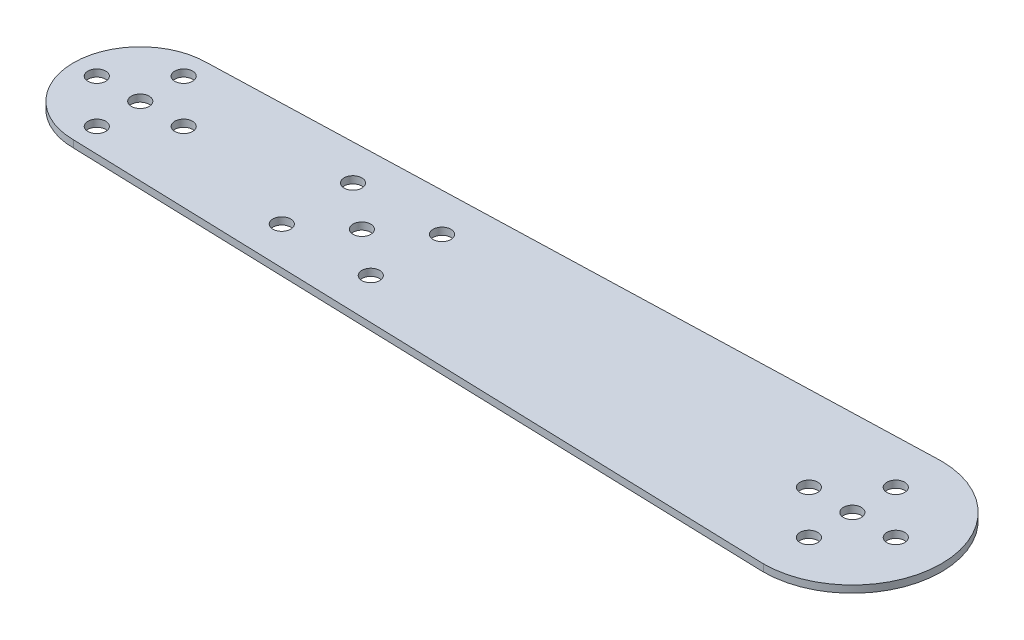
from build123d import *

# Parameters (mm, degrees)
BOSS_EXTRUDE1_DEPTH       = 2
F_5_0MM_DOWEL_HOLE1_D     = 5
F_5_0MM_DOWEL_HOLE1_DEPTH = 2
CUT_EXTRUDE1_REACH        = 4
SKETCH4_R                 = 2.5
CUT_EXTRUDE2_REACH        = 4
SKETCH16_R                = 2.5


with BuildPart() as part:
    # Sketch2 → Boss-Extrude1 (new body)
    with BuildSketch(Plane(origin=(0, 0, 0), x_dir=(1, 0, 0), z_dir=(0, 1, 0))):
        with BuildLine():
            Line((100, 25), (-100, 18.75))
            ThreePointArc((-100, 18.75), (-118.75, 0), (-100, -18.75))
            Line((-100, -18.75), (100, -25))
            ThreePointArc((100, -25), (125, 0), (100, 25))
        make_face()
    extrude(amount=BOSS_EXTRUDE1_DEPTH)

    # Ø5.0mm Dowel Hole1
    with Locations(Plane(origin=(0, 2, 0), x_dir=(1, 0, 0), z_dir=(0, 1, 0))):
        with Locations((100, 0), (-100, 0)):
            Hole(F_5_0MM_DOWEL_HOLE1_D / 2, depth=F_5_0MM_DOWEL_HOLE1_DEPTH)

    # Sketch4 → Cut-Extrude1 (cut, up to next)
    with BuildSketch(Plane(origin=(0, 2, 0), x_dir=(1, 0, 0), z_dir=(0, 1, 0)), mode=Mode.PRIVATE) as cut_extrude1_sk1:
        with Locations((100, 12.2)):
            Circle(SKETCH4_R)
    cut_extrude1_tool1 = extrude(cut_extrude1_sk1.sketch, amount=-CUT_EXTRUDE1_REACH, mode=Mode.PRIVATE) & part.part
    add(cut_extrude1_tool1.solids().sort_by_distance((100, 2, -12.2))[0], mode=Mode.SUBTRACT)
    # Sketch4 → Cut-Extrude1 (cut, up to next)
    with BuildSketch(Plane(origin=(0, 2, 0), x_dir=(1, 0, 0), z_dir=(0, 1, 0)), mode=Mode.PRIVATE) as cut_extrude1_sk2:
        with Locations((100, -12.2)):
            Circle(SKETCH4_R)
    cut_extrude1_tool2 = extrude(cut_extrude1_sk2.sketch, amount=-CUT_EXTRUDE1_REACH, mode=Mode.PRIVATE) & part.part
    add(cut_extrude1_tool2.solids().sort_by_distance((100, 2, 12.2))[0], mode=Mode.SUBTRACT)
    # Sketch4 → Cut-Extrude1 (cut, up to next)
    with BuildSketch(Plane(origin=(0, 2, 0), x_dir=(1, 0, 0), z_dir=(0, 1, 0)), mode=Mode.PRIVATE) as cut_extrude1_sk3:
        with Locations((112.2, 0)):
            Circle(SKETCH4_R)
    cut_extrude1_tool3 = extrude(cut_extrude1_sk3.sketch, amount=-CUT_EXTRUDE1_REACH, mode=Mode.PRIVATE) & part.part
    add(cut_extrude1_tool3.solids().sort_by_distance((112.2, 2, 0))[0], mode=Mode.SUBTRACT)
    # Sketch4 → Cut-Extrude1 (cut, up to next)
    with BuildSketch(Plane(origin=(0, 2, 0), x_dir=(1, 0, 0), z_dir=(0, 1, 0)), mode=Mode.PRIVATE) as cut_extrude1_sk4:
        with Locations((87.8, 0)):
            Circle(SKETCH4_R)
    cut_extrude1_tool4 = extrude(cut_extrude1_sk4.sketch, amount=-CUT_EXTRUDE1_REACH, mode=Mode.PRIVATE) & part.part
    add(cut_extrude1_tool4.solids().sort_by_distance((87.8, 2, 0))[0], mode=Mode.SUBTRACT)
    # Sketch4 → Cut-Extrude1 (cut, up to next)
    with BuildSketch(Plane(origin=(0, 2, 0), x_dir=(1, 0, 0), z_dir=(0, 1, 0)), mode=Mode.PRIVATE) as cut_extrude1_sk5:
        with Locations((-100, 12.2)):
            Circle(SKETCH4_R)
    cut_extrude1_tool5 = extrude(cut_extrude1_sk5.sketch, amount=-CUT_EXTRUDE1_REACH, mode=Mode.PRIVATE) & part.part
    add(cut_extrude1_tool5.solids().sort_by_distance((-100, 2, -12.2))[0], mode=Mode.SUBTRACT)
    # Sketch4 → Cut-Extrude1 (cut, up to next)
    with BuildSketch(Plane(origin=(0, 2, 0), x_dir=(1, 0, 0), z_dir=(0, 1, 0)), mode=Mode.PRIVATE) as cut_extrude1_sk6:
        with Locations((-87.8, 0)):
            Circle(SKETCH4_R)
    cut_extrude1_tool6 = extrude(cut_extrude1_sk6.sketch, amount=-CUT_EXTRUDE1_REACH, mode=Mode.PRIVATE) & part.part
    add(cut_extrude1_tool6.solids().sort_by_distance((-87.8, 2, 0))[0], mode=Mode.SUBTRACT)
    # Sketch4 → Cut-Extrude1 (cut, up to next)
    with BuildSketch(Plane(origin=(0, 2, 0), x_dir=(1, 0, 0), z_dir=(0, 1, 0)), mode=Mode.PRIVATE) as cut_extrude1_sk7:
        with Locations((-112.2, 0)):
            Circle(SKETCH4_R)
    cut_extrude1_tool7 = extrude(cut_extrude1_sk7.sketch, amount=-CUT_EXTRUDE1_REACH, mode=Mode.PRIVATE) & part.part
    add(cut_extrude1_tool7.solids().sort_by_distance((-112.2, 2, 0))[0], mode=Mode.SUBTRACT)
    # Sketch4 → Cut-Extrude1 (cut, up to next)
    with BuildSketch(Plane(origin=(0, 2, 0), x_dir=(1, 0, 0), z_dir=(0, 1, 0)), mode=Mode.PRIVATE) as cut_extrude1_sk8:
        with Locations((-100, -12.2)):
            Circle(SKETCH4_R)
    cut_extrude1_tool8 = extrude(cut_extrude1_sk8.sketch, amount=-CUT_EXTRUDE1_REACH, mode=Mode.PRIVATE) & part.part
    add(cut_extrude1_tool8.solids().sort_by_distance((-100, 2, 12.2))[0], mode=Mode.SUBTRACT)

    # Sketch16 → Cut-Extrude2 (cut, up to next)
    with BuildSketch(Plane(origin=(0, 2, 0), x_dir=(1, 0, 0), z_dir=(0, 1, 0)), mode=Mode.PRIVATE) as cut_extrude2_sk1:
        with Locations((-37.749999999, 0)):
            Circle(SKETCH16_R)
    cut_extrude2_tool1 = extrude(cut_extrude2_sk1.sketch, amount=-CUT_EXTRUDE2_REACH, mode=Mode.PRIVATE) & part.part
    add(cut_extrude2_tool1.solids().sort_by_distance((-37.75, 2, 0))[0], mode=Mode.SUBTRACT)
    # Sketch16 → Cut-Extrude2 (cut, up to next)
    with BuildSketch(Plane(origin=(0, 2, 0), x_dir=(1, 0, 0), z_dir=(0, 1, 0)), mode=Mode.PRIVATE) as cut_extrude2_sk2:
        with Locations((-25.249999999, 10)):
            Circle(SKETCH16_R)
    cut_extrude2_tool2 = extrude(cut_extrude2_sk2.sketch, amount=-CUT_EXTRUDE2_REACH, mode=Mode.PRIVATE) & part.part
    add(cut_extrude2_tool2.solids().sort_by_distance((-25.25, 2, -10))[0], mode=Mode.SUBTRACT)
    # Sketch16 → Cut-Extrude2 (cut, up to next)
    with BuildSketch(Plane(origin=(0, 2, 0), x_dir=(1, 0, 0), z_dir=(0, 1, 0)), mode=Mode.PRIVATE) as cut_extrude2_sk3:
        with Locations((-25.249999999, -10)):
            Circle(SKETCH16_R)
    cut_extrude2_tool3 = extrude(cut_extrude2_sk3.sketch, amount=-CUT_EXTRUDE2_REACH, mode=Mode.PRIVATE) & part.part
    add(cut_extrude2_tool3.solids().sort_by_distance((-25.25, 2, 10))[0], mode=Mode.SUBTRACT)
    # Sketch16 → Cut-Extrude2 (cut, up to next)
    with BuildSketch(Plane(origin=(0, 2, 0), x_dir=(1, 0, 0), z_dir=(0, 1, 0)), mode=Mode.PRIVATE) as cut_extrude2_sk4:
        with Locations((-50.249999999, 10)):
            Circle(SKETCH16_R)
    cut_extrude2_tool4 = extrude(cut_extrude2_sk4.sketch, amount=-CUT_EXTRUDE2_REACH, mode=Mode.PRIVATE) & part.part
    add(cut_extrude2_tool4.solids().sort_by_distance((-50.25, 2, -10))[0], mode=Mode.SUBTRACT)
    # Sketch16 → Cut-Extrude2 (cut, up to next)
    with BuildSketch(Plane(origin=(0, 2, 0), x_dir=(1, 0, 0), z_dir=(0, 1, 0)), mode=Mode.PRIVATE) as cut_extrude2_sk5:
        with Locations((-50.249999999, -10)):
            Circle(SKETCH16_R)
    cut_extrude2_tool5 = extrude(cut_extrude2_sk5.sketch, amount=-CUT_EXTRUDE2_REACH, mode=Mode.PRIVATE) & part.part
    add(cut_extrude2_tool5.solids().sort_by_distance((-50.25, 2, 10))[0], mode=Mode.SUBTRACT)


solid = part.part
